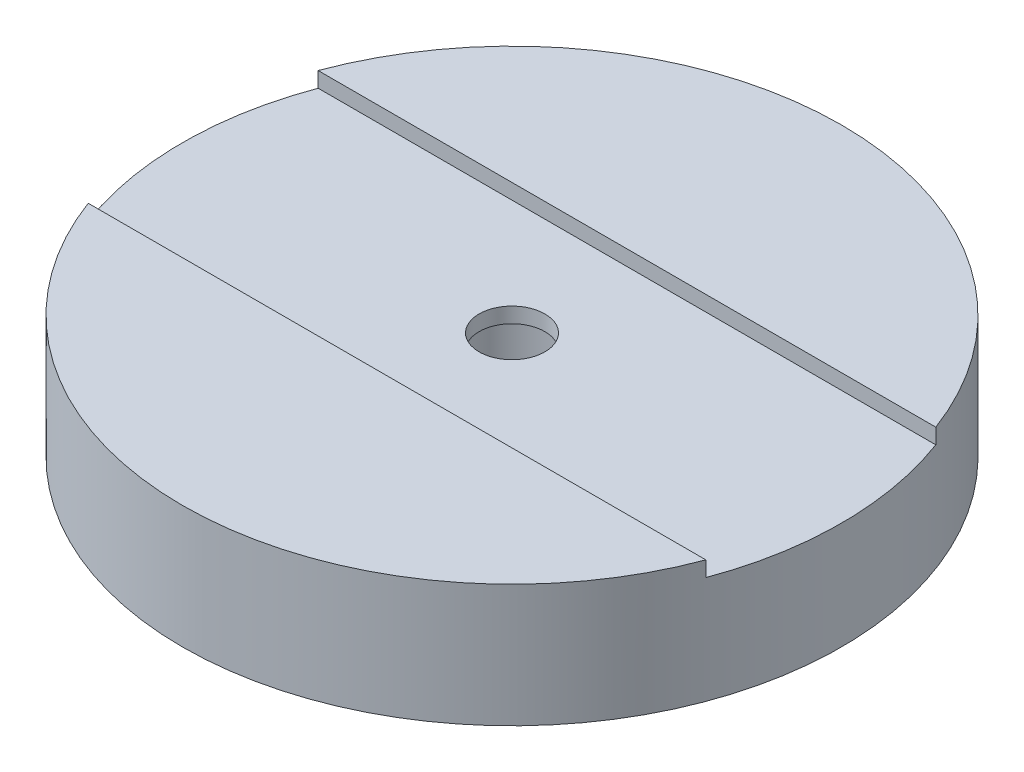
from build123d import *

# Parameters (mm, degrees)
SKETCH1_R           = 21.5
SKETCH1_R_2         = 3.935
BOSS_EXTRUDE1_DEPTH = 6
SKETCH2_R           = 21.5
SKETCH2_R_2         = 2.146170777
BOSS_EXTRUDE2_DEPTH = 2
SKETCH3_W           = 47.979392496
SKETCH3_H           = 15
CUT_EXTRUDE1_DEPTH  = 1


with BuildPart() as part:
    # Sketch1 → Boss-Extrude1 (new body)
    with BuildSketch(Plane(origin=(0, 0, 0), x_dir=(1, 0, 0), z_dir=(0, 1, 0))):
        with Locations(Location((0, 0, 0), (0, 0, 270))):  # turned: the seam where the file's is
            Circle(SKETCH1_R)
        with Locations(Location((0, 0, 0), (0, 0, 270))):  # turned: the seam where the file's is
            Circle(SKETCH1_R_2, mode=Mode.SUBTRACT)
    extrude(amount=BOSS_EXTRUDE1_DEPTH)

    # Sketch2 → Boss-Extrude2 (add)
    with BuildSketch(Plane(origin=(0, 6, 0), x_dir=(1, 0, 0), z_dir=(0, 1, 0))):
        with Locations(Location((0, 0, 0), (0, 0, 270))):  # turned: the seam where the file's is
            Circle(SKETCH2_R)
        with Locations(Location((0, 0, 0), (0, 0, 270))):  # turned: the seam where the file's is
            Circle(SKETCH2_R_2, mode=Mode.SUBTRACT)
    extrude(amount=BOSS_EXTRUDE2_DEPTH)

    # Sketch3 → Cut-Extrude1 (cut)
    with BuildSketch(Plane(origin=(0, 8, 0), x_dir=(1, 0, 0), z_dir=(0, 1, 0))):
        Rectangle(SKETCH3_W, SKETCH3_H)
    extrude(amount=-CUT_EXTRUDE1_DEPTH, mode=Mode.SUBTRACT)


solid = part.part
